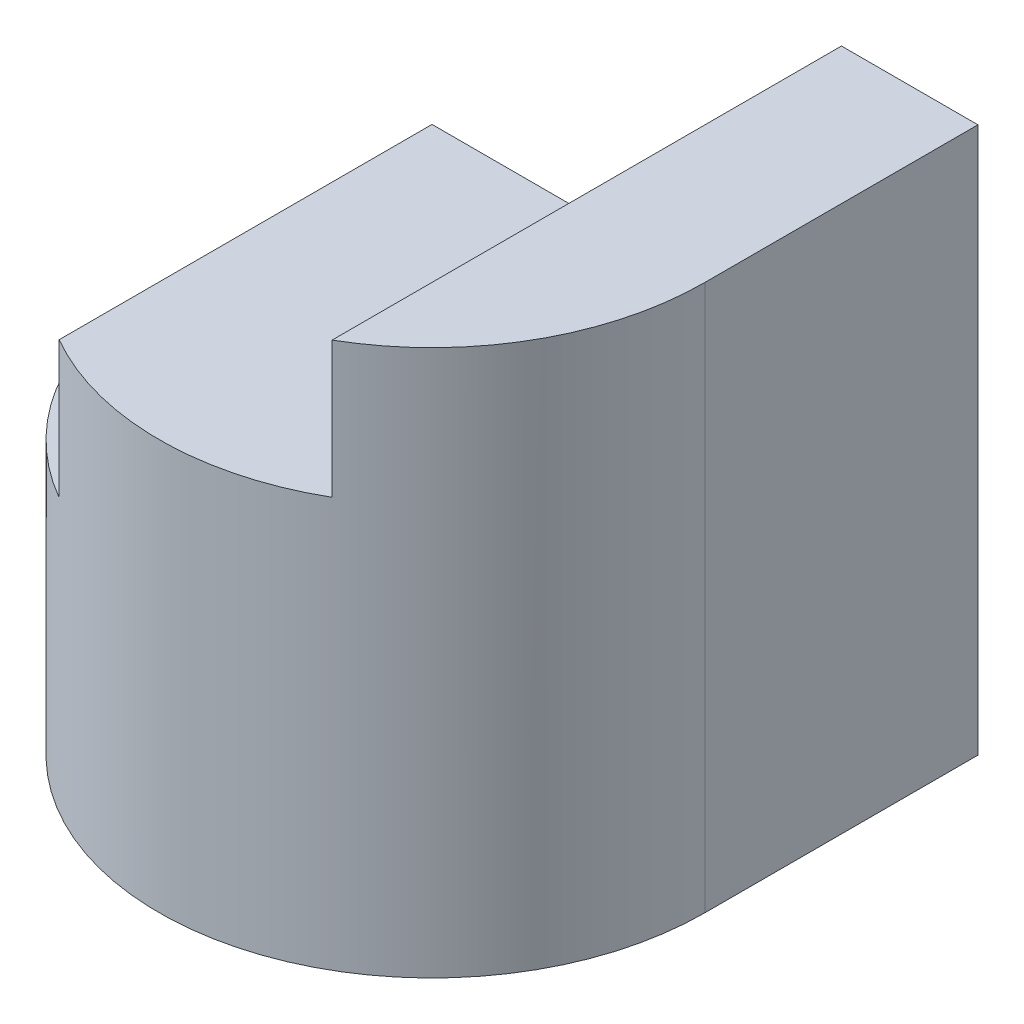
from build123d import *

# Parameters (mm, degrees)
BOSS_EXTRUDE1_DEPTH = 4
CUT_EXTRUDE1_DEPTH  = 4


with BuildPart() as part:
    # Sketch1 → Boss-Extrude1 (new body)
    with BuildSketch(Plane(origin=(0, 0, 0), x_dir=(1, 0, 0), z_dir=(0, 1, 0))):
        with BuildLine():
            Line((-2, 2), (-2, 0))
            ThreePointArc((-2, 0), (0, -2), (2, 0))
            Line((2, 0), (2, 2))
            Line((2, 2), (1, 2))
            Line((1, 2), (1, 1))
            Line((1, 1), (-1, 1))
            Line((-1, 1), (-1, 2))
            Line((-1, 2), (-2, 2))
        make_face()
    extrude(amount=BOSS_EXTRUDE1_DEPTH)

    # Sketch2 → Cut-Extrude1 (cut)
    with BuildSketch(Plane(origin=(0, 0, -2), x_dir=(-1, 0, 0), z_dir=(0, 0, -1))):
        Polygon((-1, 4), (-1, 3.002459536), (1, 3.002459536), (1, 2), (2, 2), (2, 4), align=None)
    extrude(amount=-CUT_EXTRUDE1_DEPTH, mode=Mode.SUBTRACT)


solid = part.part
